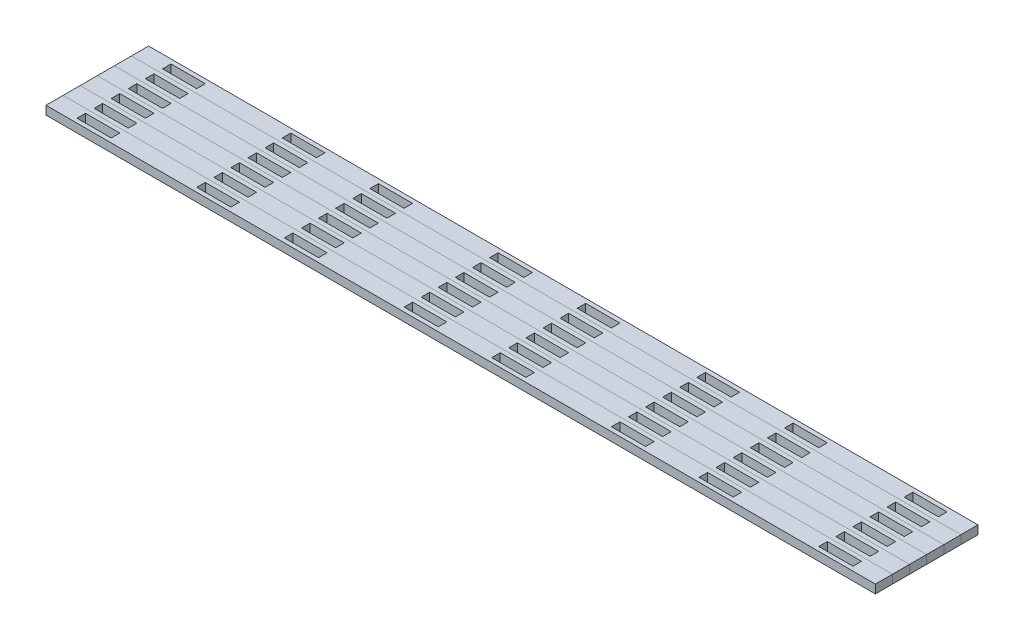
from build123d import *

# Parameters (mm, degrees)
SKETCH1_W           = 615.917267528
SKETCH1_H           = 12.7
BOSS_EXTRUDE1_DEPTH = 6.35
SKETCH2_W           = 25.4
SKETCH2_H           = 6.35
CUT_EXTRUDE1_DEPTH  = 7.35
LPATTERN1_COUNT     = 2
LPATTERN1_PITCH     = 307.958633764
LPATTERN1_COL_COUNT = 2
LPATTERN1_COL_PITCH = 307.958633764
LPATTERN2_COUNT     = 6
LPATTERN2_PITCH     = 12.7


with BuildPart() as part:
    # Sketch1 → Boss-Extrude1 (new body)
    with BuildSketch(Plane(origin=(0, 0, 0), x_dir=(1, 0, 0), z_dir=(0, 1, 0))):
        Rectangle(SKETCH1_W, SKETCH1_H)
    extrude(amount=BOSS_EXTRUDE1_DEPTH)

    # Sketch2 → Cut-Extrude1 (cut, through all)
    with BuildSketch(Plane(origin=(0, 6.35, 0), x_dir=(1, 0, 0), z_dir=(0, 1, 0))):
        with Locations((-32.539658441, 0)):
            Rectangle(SKETCH2_W, SKETCH2_H)
        with Locations((32.539658441, 0)):
            Rectangle(SKETCH2_W, SKETCH2_H)
        with Locations((-121.439658441, 0)):
            Rectangle(SKETCH2_W, SKETCH2_H)
        with Locations((121.439658441, 0)):
            Rectangle(SKETCH2_W, SKETCH2_H)
    cut_extrude1 = extrude(amount=-CUT_EXTRUDE1_DEPTH, mode=Mode.SUBTRACT)

    # LPattern1: Cut-Extrude1 ×2
    with Locations(*[(i * LPATTERN1_PITCH, 0, 0) for i in range(1, LPATTERN1_COUNT)]):
        add(cut_extrude1, mode=Mode.SUBTRACT)

    # LPattern1 col: Cut-Extrude1 ×2
    with Locations(*[(-i * LPATTERN1_COL_PITCH, 0, 0) for i in range(1, LPATTERN1_COL_COUNT)]):
        add(cut_extrude1, mode=Mode.SUBTRACT)


with BuildPart() as lpattern2_1:
    # LPattern2: pattern copy
    add(part.part.moved(Location(Vector(0, 0, 1) * (1 * LPATTERN2_PITCH))))


with BuildPart() as lpattern2_2:
    # LPattern2: pattern copy
    add(part.part.moved(Location(Vector(0, 0, 1) * (2 * LPATTERN2_PITCH))))


with BuildPart() as lpattern2_3:
    # LPattern2: pattern copy
    add(part.part.moved(Location(Vector(0, 0, 1) * (3 * LPATTERN2_PITCH))))


with BuildPart() as lpattern2_4:
    # LPattern2: pattern copy
    add(part.part.moved(Location(Vector(0, 0, 1) * (4 * LPATTERN2_PITCH))))


with BuildPart() as lpattern2_5:
    # LPattern2: pattern copy
    add(part.part.moved(Location(Vector(0, 0, 1) * (5 * LPATTERN2_PITCH))))


solid = Compound([part.part, lpattern2_1.part, lpattern2_2.part, lpattern2_3.part, lpattern2_4.part, lpattern2_5.part])
